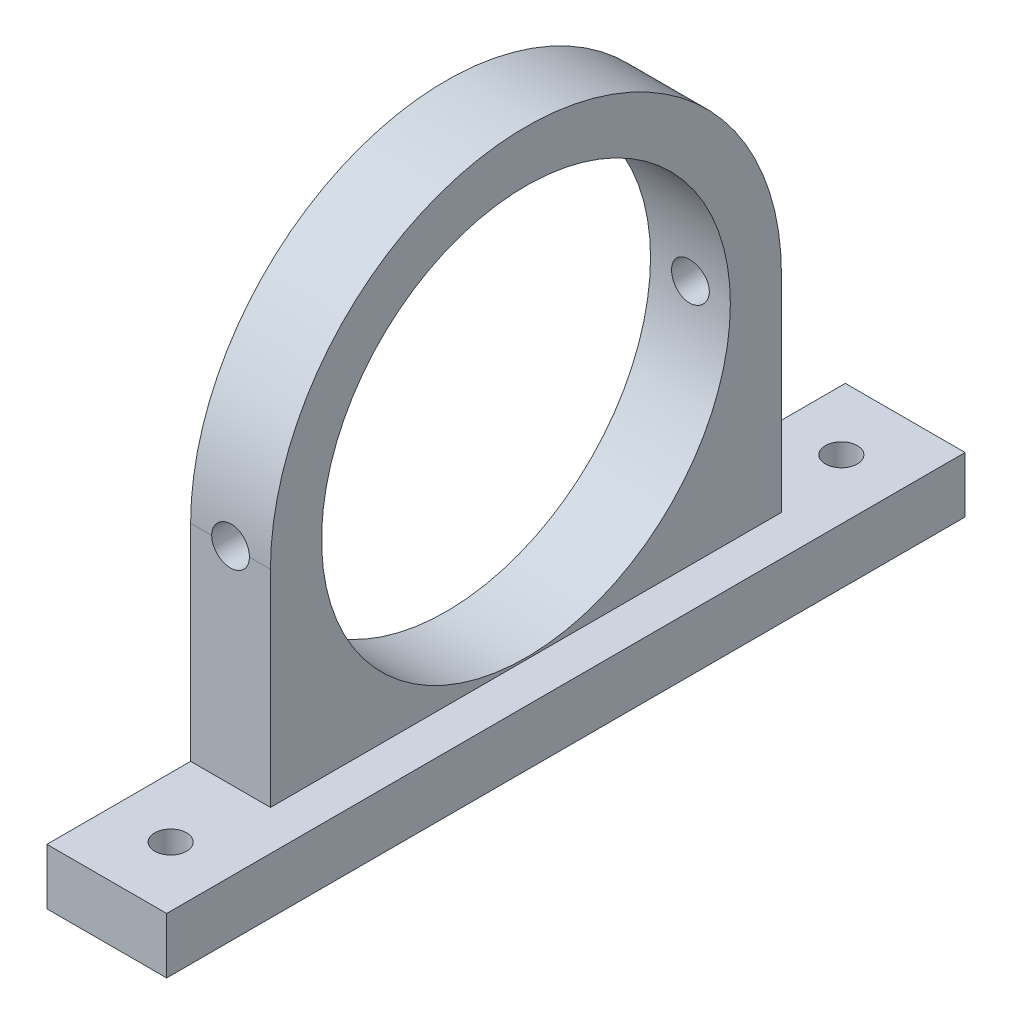
from build123d import *

# Parameters (mm, degrees)
SKETCH2_R                                         = 16.256
BOSS_EXTRUDE1_DEPTH                               = 3.175
SKETCH3_W                                         = 63.5
SKETCH3_H                                         = 4.445
BOSS_EXTRUDE2_DEPTH                               = 3.175
CSK_FOR_0_FLAT_HEAD_MACHINE_SCREW_100_D           = 3.000000096
CSK_FOR_0_FLAT_HEAD_MACHINE_SCREW_100_CSINK_D     = 3.0226
CSK_FOR_0_FLAT_HEAD_MACHINE_SCREW_100_CSINK_ANGLE = 100
SKETCH6_R                                         = 1.27
CUT_EXTRUDE1_DEPTH                                = 6.35


with BuildPart() as part:
    # Sketch2 → Boss-Extrude1 (new body, symmetric)
    with BuildSketch(Plane(origin=(0, 0, 0), x_dir=(0, 0, -1), z_dir=(1, 0, 0))):
        Polygon((-20.32, 4.445), (20.32, 4.445), (31.75, 4.445), (31.75, 0), (-31.75, 0), (-31.75, 4.445), align=None)
        with BuildLine():
            ThreePointArc((-20.32, 20.85), (0, 41.17), (20.32, 20.85))
            Line((20.32, 20.85), (20.32, 4.445))
            Line((20.32, 4.445), (-20.32, 4.445))
            Line((-20.32, 4.445), (-20.32, 20.85))
        make_face()
        with Locations((0, 20.85)):
            Circle(SKETCH2_R, mode=Mode.SUBTRACT)
    extrude(amount=BOSS_EXTRUDE1_DEPTH, both=True)

    # Sketch3 → Boss-Extrude2 (add)
    with BuildSketch(Plane(origin=(3.175, 0, 0), x_dir=(0, 0, -1), z_dir=(1, 0, 0))):
        with Locations((0, 2.2225)):
            Rectangle(SKETCH3_W, SKETCH3_H)
    extrude(amount=BOSS_EXTRUDE2_DEPTH)

    # CSK for #0 Flat Head Machine Screw (100)1 (through all)
    with Locations(Plane(origin=(0, 0, -20.32), x_dir=(-1, 0, 0), z_dir=(0, 0, -1))):
        with Locations((0, 20.85)):
            CounterSinkHole(CSK_FOR_0_FLAT_HEAD_MACHINE_SCREW_100_D / 2, CSK_FOR_0_FLAT_HEAD_MACHINE_SCREW_100_CSINK_D / 2, counter_sink_angle=CSK_FOR_0_FLAT_HEAD_MACHINE_SCREW_100_CSINK_ANGLE)

    # Sketch6 → Cut-Extrude1 (cut)
    with BuildSketch(Plane(origin=(0, 4.445, 0), x_dir=(1, 0, 0), z_dir=(0, 1, 0))):
        with Locations((1.5875, -26.67)):
            Circle(SKETCH6_R)
    cut_extrude1 = extrude(amount=-CUT_EXTRUDE1_DEPTH, mode=Mode.SUBTRACT)

    # Mirror2: Cut-Extrude1 across plane
    add(cut_extrude1.mirror(Plane.XY), mode=Mode.SUBTRACT)


solid = part.part
